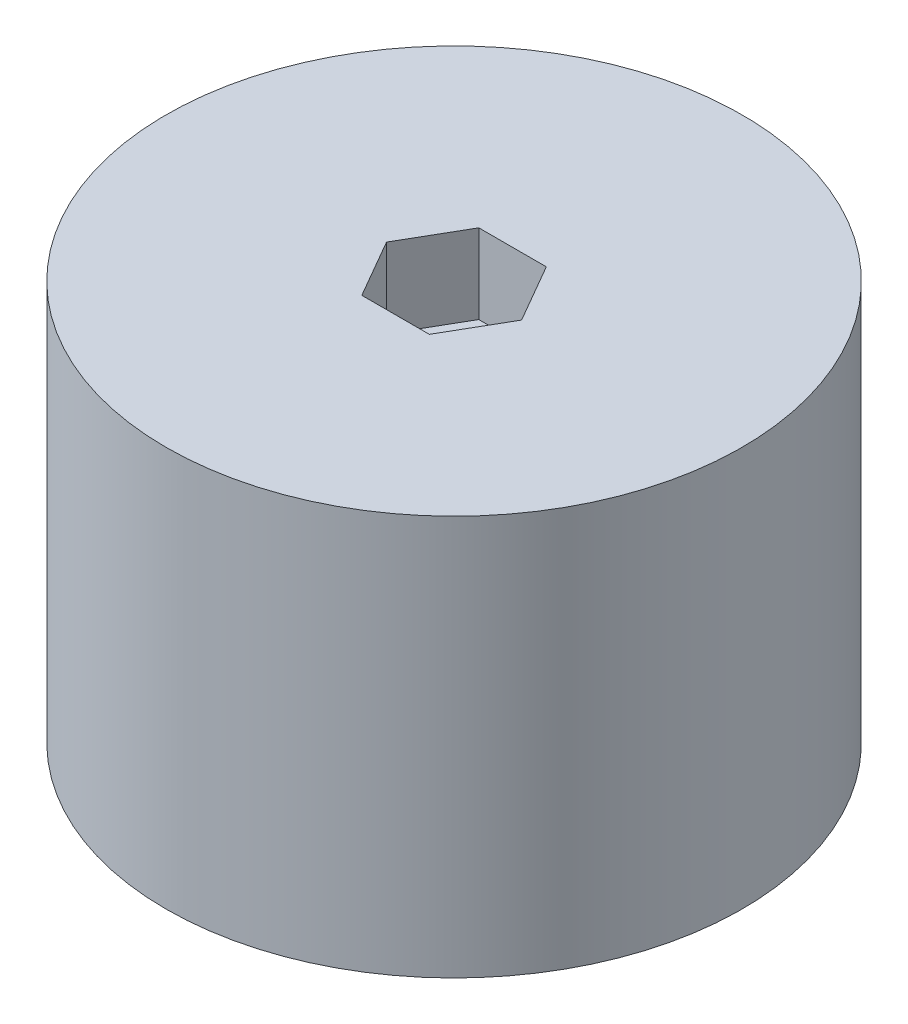
from build123d import *

# Parameters (mm, degrees)
SKETCH1_R           = 21.75
SKETCH1_R_2         = 3
BOSS_EXTRUDE1_DEPTH = 30.2
CUT_EXTRUDE1_DEPTH  = 6


with BuildPart() as part:
    # Sketch1 → Boss-Extrude1 (new body)
    with BuildSketch(Plane(origin=(0, 0, 0), x_dir=(1, 0, 0), z_dir=(0, 1, 0))):
        Circle(SKETCH1_R)
        Circle(SKETCH1_R_2, mode=Mode.SUBTRACT)
    extrude(amount=BOSS_EXTRUDE1_DEPTH)

    # Sketch2 → Cut-Extrude1 (cut)
    with BuildSketch(Plane(origin=(0, 30.2, 0), x_dir=(1, 0, 0), z_dir=(0, 1, 0))):
        Polygon((5.1, 0), (2.55, 4.416729559), (-2.55, 4.416729559), (-5.1, 0), (-2.55, -4.416729559), (2.55, -4.416729559), align=None)
    extrude(amount=-CUT_EXTRUDE1_DEPTH, mode=Mode.SUBTRACT)


solid = part.part
